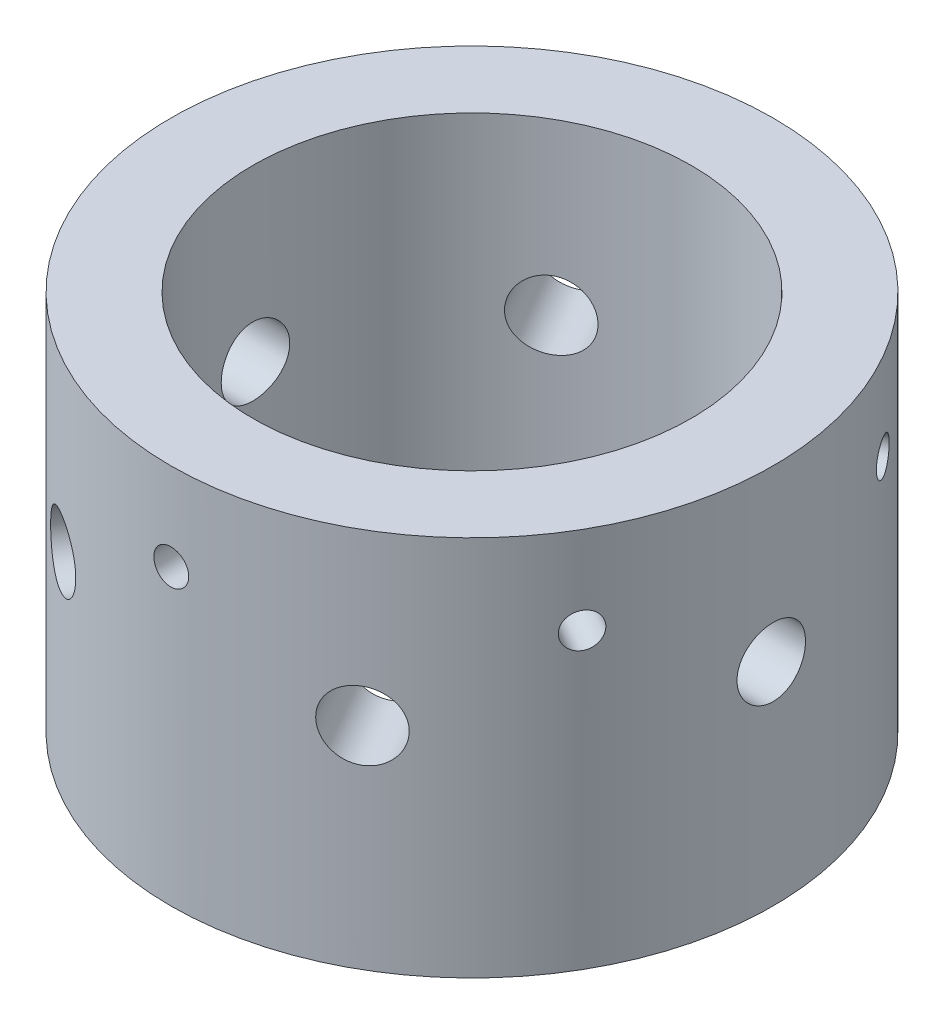
from build123d import *

# Parameters (mm, degrees)
SKETCH2_W                    = 9.4996
SKETCH2_H                    = 44.1706
F_3_8_16_TAPPED_HOLE2_REACH  = 91.671
F_3_8_16_TAPPED_HOLE2_BORE_R = 3.96875
CIRPATTERN1_COUNT            = 6
CIRPATTERN2_COUNT            = 6


with BuildPart() as part:
    # Sketch2 → Revolve1 (revolve)
    with BuildSketch(Plane.XY, mode=Mode.PRIVATE) as revolve1_sk:
        with Locations((-30.1498, 22.0853)):
            Rectangle(SKETCH2_W, SKETCH2_H)
    revolve(revolve1_sk.sketch.rotate(Axis((0, 0, 0), (0, 1, 0)), 270), axis=Axis((0, 0, 0), (0, 1, 0)))

    # 3_8-16 Tapped Hole2 bore → 3_8-16 Tapped Hole2 (cut, up to next)
    with BuildSketch(Plane(origin=(34.8996, 0, 0), x_dir=(0, 0, -1), z_dir=(1, 0, 0)), mode=Mode.PRIVATE) as f_3_8_16_tapped_hole2_sk1:
        with Locations((0, 24.4856)):
            Circle(F_3_8_16_TAPPED_HOLE2_BORE_R)
    f_3_8_16_tapped_hole2_tool1 = extrude(f_3_8_16_tapped_hole2_sk1.sketch, amount=-F_3_8_16_TAPPED_HOLE2_REACH, mode=Mode.PRIVATE) & part.part
    f_3_8_16_tapped_hole2 = f_3_8_16_tapped_hole2_tool1.solids().sort_by_distance((34.8996, 24.4856, 0))[0]
    add(f_3_8_16_tapped_hole2, mode=Mode.SUBTRACT)

    # CirPattern1: 3_8-16 Tapped Hole2 ×6 about axis
    cirpattern1_axis = Axis((0, 44.1706, 0), (0, -1, 0))
    for i in range(1, CIRPATTERN1_COUNT):
        add(f_3_8_16_tapped_hole2.rotate(cirpattern1_axis, i * 360 / CIRPATTERN1_COUNT), mode=Mode.SUBTRACT)

    # Sketch14 → Tap Drill for _10-32 Tap1 (revolve, cut)
    with BuildSketch(Plane(origin=(0, 34.036, 34.8996), x_dir=(0, -1, 0), z_dir=(1, 0, 0))):
        Polygon((0, 0), (0, 8.833317848), (2.0193, 7.62), (2.0193, 0), align=None)
    tap_drill_for_10_32_tap1 = revolve(axis=Axis((0, 34.036, 41.2496), (0, 0, -1)), mode=Mode.SUBTRACT)

    # CirPattern2: Tap Drill for _10-32 Tap1 ×6 about axis
    cirpattern2_axis = Axis((0, 0, 0), (0, -1, 0))
    for i in range(1, CIRPATTERN2_COUNT):
        add(tap_drill_for_10_32_tap1.rotate(cirpattern2_axis, i * 360 / CIRPATTERN2_COUNT), mode=Mode.SUBTRACT)


solid = part.part
